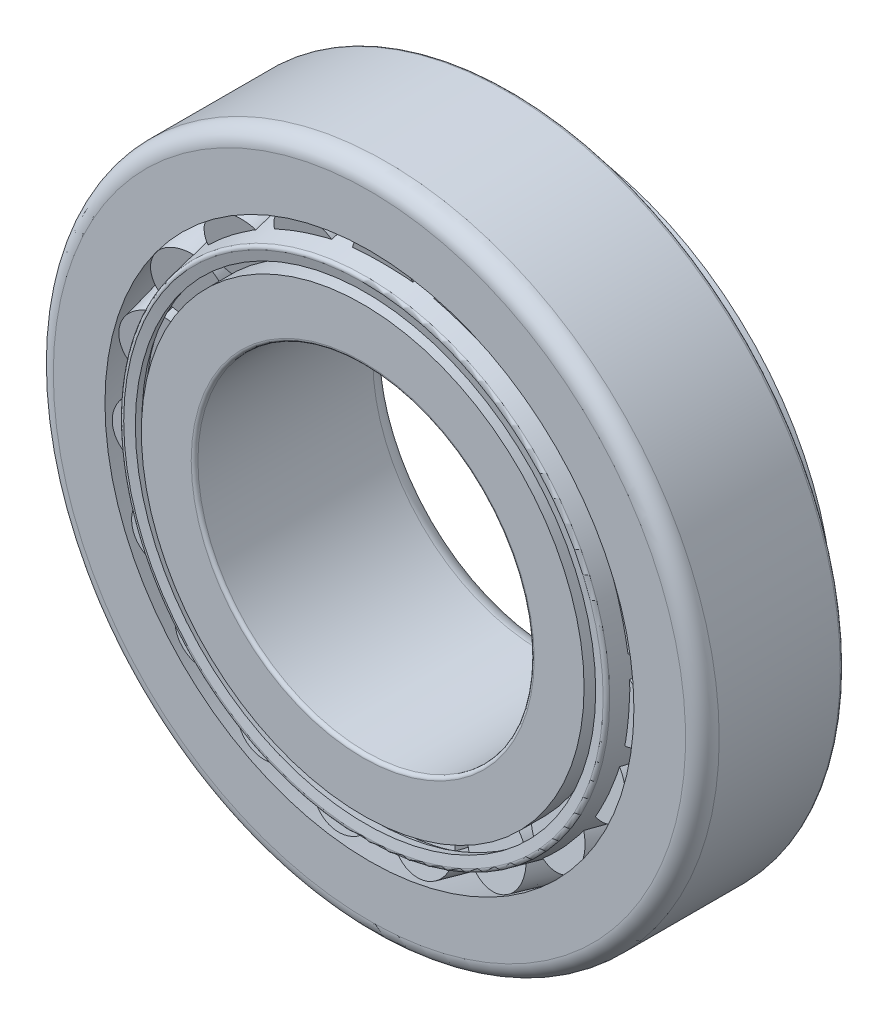
from build123d import *

# Parameters (mm, degrees)
CIRPATTERN1_COUNT = 19
FILLET1_R         = 1.27
FILLET2_R         = 1.27
FILLET3_R         = 0.254
FILLET4_R         = 0.254
FILLET5_R         = 0.254


with BuildPart() as part:
    # Sketch2 → Revolve1 (revolve)
    with BuildSketch(Plane(origin=(0, 0, 0), x_dir=(0, 0, -1), z_dir=(1, 0, 0))):
        Polygon((-5.334, 25.146), (-5.334, 19.975), (5.334, 22.635), (5.334, 25.146), align=None)
    revolve(axis=Axis((0, 0, 0), (0, 0, -1)))

    # Fillet2
    fillet2_edges = [part.edges().sort_by_distance(p)[0] for p in [
        (0, -25.146, 5.334),
    ]]
    fillet(fillet2_edges, radius=FILLET2_R)

    # Fillet4
    fillet4_edges = [part.edges().sort_by_distance(p)[0] for p in [
        (0, -25.146, -5.334),
    ]]
    fillet(fillet4_edges, radius=FILLET4_R)


with BuildPart() as body_2:
    # Sketch3 → Revolve2 (revolve)
    with BuildSketch(Plane(origin=(0, 0, 0), x_dir=(0, 0, -1), z_dir=(1, 0, 0))):
        Polygon((-5.842, 16.72), (-5.842, 12.7), (8.89, 12.7), (8.89, 18.63), (5.524233262, 18.63), (5.831160511, 17.2268764), (-3.655767129, 15.438272488), (-3.936139506, 16.72), align=None)
    revolve(axis=Axis((0, 0, 0), (0, 0, -1)))

    # Fillet1
    fillet1_edges = [body_2.edges().sort_by_distance(p)[0] for p in [
        (0, -12.7, -8.89),
    ]]
    fillet(fillet1_edges, radius=FILLET1_R)

    # Fillet3
    fillet3_edges = [body_2.edges().sort_by_distance(p)[0] for p in [
        (0, -12.7, 5.842),
    ]]
    fillet(fillet3_edges, radius=FILLET3_R)


with BuildPart() as body_3:
    # Sketch4 → Revolve3 (revolve)
    with BuildSketch(Plane(origin=(0, 0, 0), x_dir=(0, 0, -1), z_dir=(1, 0, 0))):
        Polygon((8.382, 20.789260495), (8.240962708, 21.434015085), (-5.842, 18.353427601), (-5.630444062, 17.386295715), (-4.985689471, 17.527333007), (-5.056208117, 17.849710302), align=None)
    revolve(axis=Axis((0, 0, 0), (0, 0, -1)))

    # Fillet5
    fillet5_edges = [body_3.edges().sort_by_distance(p)[0] for p in [
        (0, -18.353427601, 5.842),
    ]]
    fillet(fillet5_edges, radius=FILLET5_R)


with BuildPart() as body_4:
    # Sketch6 → Revolve4 (revolve)
    with BuildSketch(Plane(origin=(0, 0, 0), x_dir=(0, 0, -1), z_dir=(1, 0, 0))):
        Polygon((5.831160511, 17.2268764), (5.257395164, 19.849855303), (-4.169698473, 17.787719141), (-3.655767129, 15.438272488), align=None)
    revolve(axis=Axis((0, 17.787719141, 4.169698473), (0, 0.21369286655434244, -0.976900895067554)))


with BuildPart() as cirpattern1_1:
    # CirPattern1: pattern copy
    add(body_4.part.rotate(Axis((0, 0, 0), (0, 0, -1)), 1 * 360 / CIRPATTERN1_COUNT))


with BuildPart() as cirpattern1_2:
    # CirPattern1: pattern copy
    add(body_4.part.rotate(Axis((0, 0, 0), (0, 0, -1)), 2 * 360 / CIRPATTERN1_COUNT))


with BuildPart() as cirpattern1_3:
    # CirPattern1: pattern copy
    add(body_4.part.rotate(Axis((0, 0, 0), (0, 0, -1)), 3 * 360 / CIRPATTERN1_COUNT))


with BuildPart() as cirpattern1_4:
    # CirPattern1: pattern copy
    add(body_4.part.rotate(Axis((0, 0, 0), (0, 0, -1)), 4 * 360 / CIRPATTERN1_COUNT))


with BuildPart() as cirpattern1_5:
    # CirPattern1: pattern copy
    add(body_4.part.rotate(Axis((0, 0, 0), (0, 0, -1)), 5 * 360 / CIRPATTERN1_COUNT))


with BuildPart() as cirpattern1_6:
    # CirPattern1: pattern copy
    add(body_4.part.rotate(Axis((0, 0, 0), (0, 0, -1)), 6 * 360 / CIRPATTERN1_COUNT))


with BuildPart() as cirpattern1_7:
    # CirPattern1: pattern copy
    add(body_4.part.rotate(Axis((0, 0, 0), (0, 0, -1)), 7 * 360 / CIRPATTERN1_COUNT))


with BuildPart() as cirpattern1_8:
    # CirPattern1: pattern copy
    add(body_4.part.rotate(Axis((0, 0, 0), (0, 0, -1)), 8 * 360 / CIRPATTERN1_COUNT))


with BuildPart() as cirpattern1_9:
    # CirPattern1: pattern copy
    add(body_4.part.rotate(Axis((0, 0, 0), (0, 0, -1)), 9 * 360 / CIRPATTERN1_COUNT))


with BuildPart() as cirpattern1_10:
    # CirPattern1: pattern copy
    add(body_4.part.rotate(Axis((0, 0, 0), (0, 0, -1)), 10 * 360 / CIRPATTERN1_COUNT))


with BuildPart() as cirpattern1_11:
    # CirPattern1: pattern copy
    add(body_4.part.rotate(Axis((0, 0, 0), (0, 0, -1)), 11 * 360 / CIRPATTERN1_COUNT))


with BuildPart() as cirpattern1_12:
    # CirPattern1: pattern copy
    add(body_4.part.rotate(Axis((0, 0, 0), (0, 0, -1)), 12 * 360 / CIRPATTERN1_COUNT))


with BuildPart() as cirpattern1_13:
    # CirPattern1: pattern copy
    add(body_4.part.rotate(Axis((0, 0, 0), (0, 0, -1)), 13 * 360 / CIRPATTERN1_COUNT))


with BuildPart() as cirpattern1_14:
    # CirPattern1: pattern copy
    add(body_4.part.rotate(Axis((0, 0, 0), (0, 0, -1)), 14 * 360 / CIRPATTERN1_COUNT))


with BuildPart() as cirpattern1_15:
    # CirPattern1: pattern copy
    add(body_4.part.rotate(Axis((0, 0, 0), (0, 0, -1)), 15 * 360 / CIRPATTERN1_COUNT))


with BuildPart() as cirpattern1_16:
    # CirPattern1: pattern copy
    add(body_4.part.rotate(Axis((0, 0, 0), (0, 0, -1)), 16 * 360 / CIRPATTERN1_COUNT))


with BuildPart() as cirpattern1_17:
    # CirPattern1: pattern copy
    add(body_4.part.rotate(Axis((0, 0, 0), (0, 0, -1)), 17 * 360 / CIRPATTERN1_COUNT))


with BuildPart() as cirpattern1_18:
    # CirPattern1: pattern copy
    add(body_4.part.rotate(Axis((0, 0, 0), (0, 0, -1)), 18 * 360 / CIRPATTERN1_COUNT))


solid = Compound([part.part, body_2.part, body_3.part, body_4.part, cirpattern1_1.part, cirpattern1_2.part, cirpattern1_3.part, cirpattern1_4.part, cirpattern1_5.part, cirpattern1_6.part, cirpattern1_7.part, cirpattern1_8.part, cirpattern1_9.part, cirpattern1_10.part, cirpattern1_11.part, cirpattern1_12.part, cirpattern1_13.part, cirpattern1_14.part, cirpattern1_15.part, cirpattern1_16.part, cirpattern1_17.part, cirpattern1_18.part])
